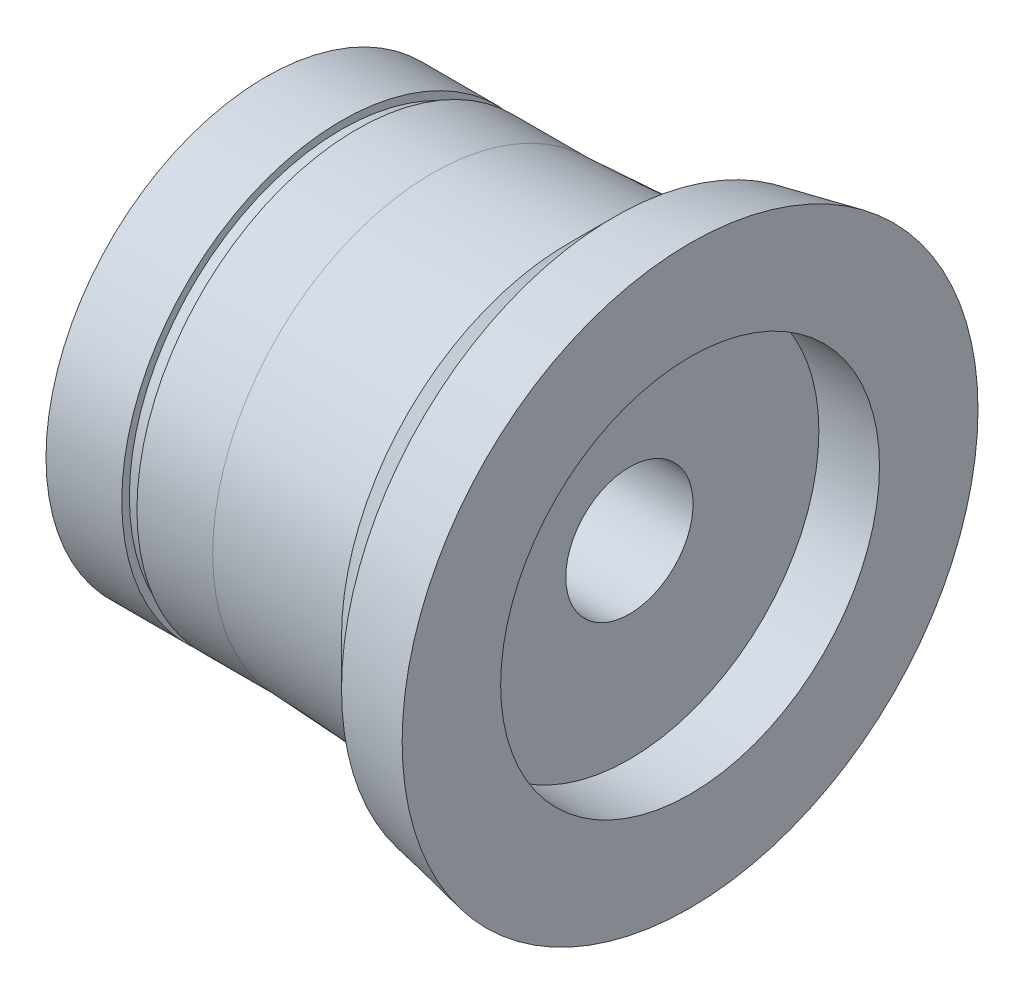
from build123d import *


with BuildPart() as part:
    # Esquisse1 → Révolution1 (revolve)
    with BuildSketch(Plane.XY, mode=Mode.PRIVATE) as r_volution1_sk:
        Polygon((0, 9.5), (0, 6.25), (-2, 6.25), (-2, 2.1), (-11, 2.1), (-11, 5), (-14, 5), (-14, 7.25), (-11.5, 7.25), (-11.5, 7), (-11, 7), (-11, 7.25), (-8.5, 7.25), (-4, 7.5), (-2.5, 9), align=None)
    revolve(r_volution1_sk.sketch.rotate(Axis((-14.253108504, 0, 0), (1, 0, 0)), 90), axis=Axis((-14.253108504, 0, 0), (1, 0, 0)))  # turned: the seam where the file's is


solid = part.part
